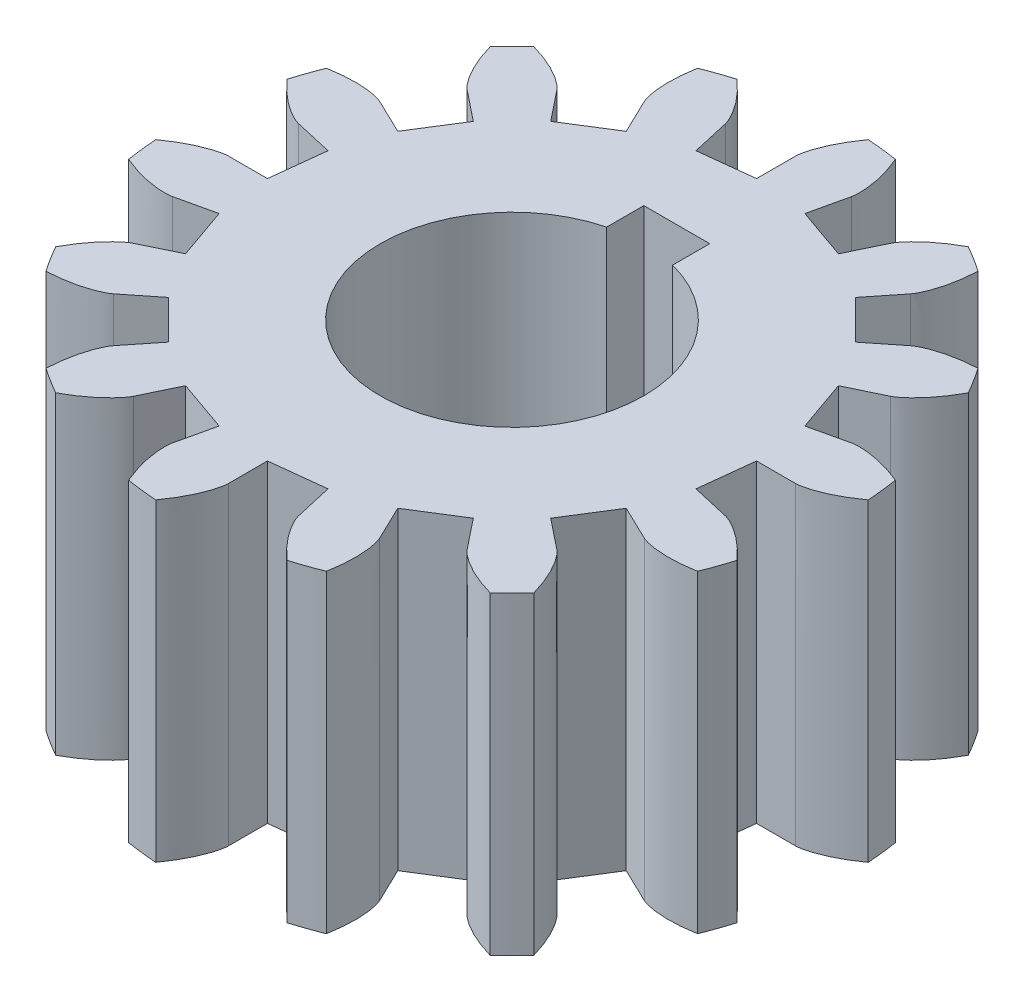
from build123d import *

# Parameters (mm, degrees)
EXTRUDE1_DEPTH = 9.525


with BuildPart() as part:
    # Sketch1 → Extrude1 (new body)
    with BuildSketch(Plane(origin=(0, 0, 0), x_dir=(1, 0, 0), z_dir=(0, 1, 0))):
        with BuildLine():
            Line((-8.606832516, 0.000361307), (-7.420609993, 0.00031151))
            Line((-7.420609993, 0.00031151), (-7.23449049, 1.651544767))
            Line((-7.23449049, 1.651544767), (-8.390960857, 1.915552658))
            add(Edge.make_bspline(
                [(-9.734164993, 2.910606791), (-9.702640301, 2.874721393), (-9.615405681, 2.777030976), (-9.471436244, 2.630567585), (-9.305885248, 2.477164851), (-9.149280434, 2.346244393), (-9.003474536, 2.236233765), (-8.870105965, 2.145762103), (-8.750724618, 2.073252804), (-8.646732539, 2.017110172), (-8.559453592, 1.975444852), (-8.489935237, 1.946810097), (-8.436064686, 1.927132829), (-8.404839359, 1.919115891), (-8.390960857, 1.915552658)],
                knots=[0.068877552, 0.068877552, 0.068877552, 0.068877552, 0.148294695, 0.284329409, 0.408535099, 0.520911772, 0.621459441, 0.710178123, 0.787067842, 0.852128636, 0.905360569, 0.946763757, 0.976338459, 1, 1, 1, 1], degree=3))
            ThreePointArc((-9.734164993, 2.910606791), (-9.589713761, 3.35603784), (-9.424891766, 3.794339891))
            add(Edge.make_bspline(
                [(-9.424891766, 3.794339891), (-9.377869884, 3.802736953), (-9.248756288, 3.82471366), (-9.044875942, 3.849442758), (-8.819796518, 3.866139589), (-8.615729979, 3.870838688), (-8.433144244, 3.86592464), (-8.272465382, 3.8534908), (-8.133921968, 3.835736168), (-8.017615087, 3.814782479), (-7.923401591, 3.792932295), (-7.851198234, 3.7719698), (-7.796813494, 3.753761803), (-7.76740318, 3.740558555), (-7.754331383, 3.7346902)],
                knots=[0.068877552, 0.068877552, 0.068877552, 0.068877552, 0.148294695, 0.284329409, 0.408535099, 0.520911772, 0.621459441, 0.710178123, 0.787067842, 0.852128636, 0.905360569, 0.946763757, 0.976338459, 1, 1, 1, 1], degree=3))
            Line((-7.754331383, 3.7346902), (-6.685603426, 3.219962672))
            Line((-6.685603426, 3.219962672), (-5.801472288, 4.626918203))
            Line((-5.801472288, 4.626918203), (-6.728867354, 5.366554781))
            add(Edge.make_bspline(
                [(-7.507314656, 6.845862009), (-7.494481981, 6.799852332), (-7.458272587, 6.673986625), (-7.392108691, 6.479561671), (-7.309511348, 6.269520698), (-7.225219545, 6.083617159), (-7.141584792, 5.9212382), (-7.060678046, 5.781859595), (-6.984579774, 5.664733349), (-6.915245523, 5.569030113), (-6.854687814, 5.493622042), (-6.804478095, 5.437660135), (-6.764480052, 5.396557972), (-6.739825424, 5.375786799), (-6.728867354, 5.366554781)],
                knots=[0.068877552, 0.068877552, 0.068877552, 0.068877552, 0.148294695, 0.284329409, 0.408535099, 0.520911772, 0.621459441, 0.710178123, 0.787067842, 0.852128636, 0.905360569, 0.946763757, 0.976338459, 1, 1, 1, 1], degree=3))
            ThreePointArc((-7.507314656, 6.845862009), (-7.183903304, 7.184506477), (-6.845231685, 7.507889396))
            add(Edge.make_bspline(
                [(-6.845231685, 7.507889396), (-6.799223085, 7.495052858), (-6.673360418, 7.458832897), (-6.47894102, 7.392652677), (-6.268906983, 7.3100377), (-6.083010522, 7.225730289), (-5.920638585, 7.142081904), (-5.781266773, 7.061163455), (-5.664146916, 6.98505535), (-5.568449502, 6.915713064), (-5.493046515, 6.855149024), (-5.437088824, 6.804934607), (-5.39599002, 6.764933114), (-5.375220917, 6.740276742), (-5.365989819, 6.729317896)],
                knots=[0.068877552, 0.068877552, 0.068877552, 0.068877552, 0.148294695, 0.284329409, 0.408535099, 0.520911772, 0.621459441, 0.710178123, 0.787067842, 0.852128636, 0.905360569, 0.946763757, 0.976338459, 1, 1, 1, 1], degree=3))
            Line((-5.365989819, 6.729317896), (-4.626431106, 5.801860736))
            Line((-4.626431106, 5.801860736), (-3.219401349, 6.685873744))
            Line((-3.219401349, 6.685873744), (-3.734039148, 7.754644913))
            add(Edge.make_bspline(
                [(-3.793548581, 9.425210298), (-3.801949591, 9.378189122), (-3.823937138, 9.249077371), (-3.848683353, 9.045199102), (-3.865399082, 8.820121081), (-3.870115313, 8.616054937), (-3.865216595, 8.433468791), (-3.852796245, 8.272788885), (-3.835053245, 8.134243981), (-3.814109321, 8.017935341), (-3.792267047, 7.923720011), (-3.771310615, 7.851514894), (-3.753107183, 7.797128625), (-3.739906405, 7.767717203), (-3.734039148, 7.754644913)],
                knots=[0.068877552, 0.068877552, 0.068877552, 0.068877552, 0.148294695, 0.284329409, 0.408535099, 0.520911772, 0.621459441, 0.710178123, 0.787067842, 0.852128636, 0.905360569, 0.946763757, 0.976338459, 1, 1, 1, 1], degree=3))
            ThreePointArc((-3.793548581, 9.425210298), (-3.355232693, 9.589995494), (-2.909789518, 9.734409328))
            add(Edge.make_bspline(
                [(-2.909789518, 9.734409328), (-2.873906766, 9.702881623), (-2.776223674, 9.615638802), (-2.629772371, 9.471657069), (-2.476383537, 9.306093193), (-2.345476227, 9.149477388), (-2.235477842, 9.003662254), (-2.145017377, 8.870286088), (-2.072518102, 8.750898654), (-2.016384201, 8.646901862), (-1.974726209, 8.559619417), (-1.94609729, 8.490098658), (-1.926424545, 8.436226455), (-1.918410229, 8.405000455), (-1.914848162, 8.391121654)],
                knots=[0.068877552, 0.068877552, 0.068877552, 0.068877552, 0.148294695, 0.284329409, 0.408535099, 0.520911772, 0.621459441, 0.710178123, 0.787067842, 0.852128636, 0.905360569, 0.946763757, 0.976338459, 1, 1, 1, 1], degree=3))
            Line((-1.914848162, 8.391121654), (-1.650937366, 7.234629126))
            Line((-1.650937366, 7.234629126), (0.00031151, 7.420609993))
            Line((0.00031151, 7.420609993), (0.000361307, 8.606832516))
            add(Edge.make_bspline(
                [(0.671576316, 10.137780095), (0.643605544, 10.09906054), (0.567775959, 9.992274912), (0.457020924, 9.819323919), (0.344302879, 9.623788312), (0.25151272, 9.441977365), (0.176705153, 9.275347458), (0.118179103, 9.125190877), (0.074052613, 8.992667832), (0.042458008, 8.878790141), (0.021258718, 8.784428053), (0.008811185, 8.710280836), (0.001614592, 8.653382328), (0.000746944, 8.621155949), (0.000361307, 8.606832516)],
                knots=[0.068877552, 0.068877552, 0.068877552, 0.068877552, 0.148294695, 0.284329409, 0.408535099, 0.520911772, 0.621459441, 0.710178123, 0.787067842, 0.852128636, 0.905360569, 0.946763757, 0.976338459, 1, 1, 1, 1], degree=3))
            ThreePointArc((0.671576316, 10.137780095), (1.137982902, 10.09606829), (1.60197215, 10.032910108))
            add(Edge.make_bspline(
                [(1.60197215, 10.032910108), (1.620622033, 9.988935685), (1.670778216, 9.867949514), (1.740254949, 9.674683616), (1.80661804, 9.458962797), (1.856608399, 9.26105828), (1.892446705, 9.081956873), (1.916079017, 8.922539775), (1.929598341, 8.783519157), (1.935050721, 8.665465698), (1.934712841, 8.568752207), (1.930342678, 8.493694545), (1.924692937, 8.436621683), (1.918365133, 8.405010748), (1.915552658, 8.390960857)],
                knots=[0.068877552, 0.068877552, 0.068877552, 0.068877552, 0.148294695, 0.284329409, 0.408535099, 0.520911772, 0.621459441, 0.710178123, 0.787067842, 0.852128636, 0.905360569, 0.946763757, 0.976338459, 1, 1, 1, 1], degree=3))
            Line((1.915552658, 8.390960857), (1.651544767, 7.23449049))
            Line((1.651544767, 7.23449049), (3.219962672, 6.685603426))
            Line((3.219962672, 6.685603426), (3.7346902, 7.754331383))
            add(Edge.make_bspline(
                [(5.003687287, 8.842438212), (4.961686707, 8.819689162), (4.847034064, 8.756379859), (4.672206602, 8.648611207), (4.485811433, 8.521346239), (4.323325574, 8.397800378), (4.183628278, 8.280129806), (4.06574763, 8.170236903), (3.968491443, 8.069983532), (3.890616009, 7.981091662), (3.830573933, 7.905272386), (3.787187821, 7.843868834), (3.756016578, 7.795727535), (3.741252352, 7.767069029), (3.7346902, 7.754331383)],
                knots=[0.068877552, 0.068877552, 0.068877552, 0.068877552, 0.148294695, 0.284329409, 0.408535099, 0.520911772, 0.621459441, 0.710178123, 0.787067842, 0.852128636, 0.905360569, 0.946763757, 0.976338459, 1, 1, 1, 1], degree=3))
            ThreePointArc((5.003687287, 8.842438212), (5.405807027, 8.602490941), (5.796443586, 8.344269995))
            add(Edge.make_bspline(
                [(5.796443586, 8.344269995), (5.794166763, 8.296558528), (5.786861991, 8.165791802), (5.765603433, 7.96152042), (5.731796756, 7.738368813), (5.690968962, 7.538373), (5.645548971, 7.36145855), (5.597672463, 7.207575032), (5.549534167, 7.076455968), (5.503225115, 6.967727777), (5.460958285, 6.880738534), (5.424454606, 6.81501006), (5.394601378, 6.766040519), (5.375184753, 6.740305582), (5.366554781, 6.728867354)],
                knots=[0.068877552, 0.068877552, 0.068877552, 0.068877552, 0.148294695, 0.284329409, 0.408535099, 0.520911772, 0.621459441, 0.710178123, 0.787067842, 0.852128636, 0.905360569, 0.946763757, 0.976338459, 1, 1, 1, 1], degree=3))
            Line((5.366554781, 6.728867354), (4.626918203, 5.801472288))
            Line((4.626918203, 5.801472288), (5.801860736, 4.626431106))
            Line((5.801860736, 4.626431106), (6.729317896, 5.365989819))
            add(Edge.make_bspline(
                [(8.344756625, 5.795742996), (8.297044967, 5.793470179), (8.166277628, 5.786176385), (7.962004462, 5.764934978), (7.738850017, 5.731147037), (7.538850777, 5.690336034), (7.361932514, 5.644930897), (7.208044977, 5.597067308), (7.076921872, 5.548940021), (6.968189794, 5.502640098), (6.881197002, 5.460380571), (6.815465463, 5.423882411), (6.766493416, 5.394033294), (6.740756849, 5.37461883), (6.729317896, 5.365989819)],
                knots=[0.068877552, 0.068877552, 0.068877552, 0.068877552, 0.148294695, 0.284329409, 0.408535099, 0.520911772, 0.621459441, 0.710178123, 0.787067842, 0.852128636, 0.905360569, 0.946763757, 0.976338459, 1, 1, 1, 1], degree=3))
            ThreePointArc((8.344756625, 5.795742996), (8.602944772, 5.405084758), (8.842858281, 5.002944874))
            add(Edge.make_bspline(
                [(8.842858281, 5.002944874), (8.820105705, 4.960946204), (8.756786776, 4.846298877), (8.649003447, 4.671480464), (8.52172283, 4.48509598), (8.398163327, 4.322620495), (8.280481026, 4.182933079), (8.170578227, 4.065061658), (8.070316691, 3.967813887), (7.981418283, 3.889945917), (7.905593967, 3.829910207), (7.844186772, 3.786529251), (7.796042856, 3.75536205), (7.76738311, 3.74060023), (7.754644913, 3.734039148)],
                knots=[0.068877552, 0.068877552, 0.068877552, 0.068877552, 0.148294695, 0.284329409, 0.408535099, 0.520911772, 0.621459441, 0.710178123, 0.787067842, 0.852128636, 0.905360569, 0.946763757, 0.976338459, 1, 1, 1, 1], degree=3))
            Line((7.754644913, 3.734039148), (6.685873744, 3.219401349))
            Line((6.685873744, 3.219401349), (7.234629126, 1.650937366))
            Line((7.234629126, 1.650937366), (8.391121654, 1.914848162))
            add(Edge.make_bspline(
                [(10.033044571, 1.601129799), (9.989071714, 1.619783374), (9.868089755, 1.669949715), (9.67482969, 1.739442674), (9.459114444, 1.805823876), (9.261214125, 1.855830851), (9.082115727, 1.891684193), (8.922700614, 1.91532989), (8.783681131, 1.928860885), (8.66562813, 1.934323177), (8.568914612, 1.933993417), (8.493856583, 1.929629556), (8.436783247, 1.923984607), (8.405171781, 1.917659457), (8.391121654, 1.914848162)],
                knots=[0.068877552, 0.068877552, 0.068877552, 0.068877552, 0.148294695, 0.284329409, 0.408535099, 0.520911772, 0.621459441, 0.710178123, 0.787067842, 0.852128636, 0.905360569, 0.946763757, 0.976338459, 1, 1, 1, 1], degree=3))
            ThreePointArc((10.033044571, 1.601129799), (10.096163797, 1.13713525), (10.137836443, 0.670725164))
            add(Edge.make_bspline(
                [(10.137836443, 0.670725164), (10.099114541, 0.642757643), (9.992322546, 0.566937024), (9.819362255, 0.45619651), (9.623817185, 0.343494882), (9.441998449, 0.250719988), (9.275362261, 0.175926411), (9.125200767, 0.117412968), (8.992674018, 0.073297605), (8.878793674, 0.041712561), (8.784429807, 0.020521193), (8.710281545, 0.008079886), (8.653382434, 0.00088807), (8.621155982, 2.3128e-05), (8.606832516, -0.000361307)],
                knots=[0.068877552, 0.068877552, 0.068877552, 0.068877552, 0.148294695, 0.284329409, 0.408535099, 0.520911772, 0.621459441, 0.710178123, 0.787067842, 0.852128636, 0.905360569, 0.946763757, 0.976338459, 1, 1, 1, 1], degree=3))
            Line((8.606832516, -0.000361307), (7.420609993, -0.00031151))
            Line((7.420609993, -0.00031151), (7.23449049, -1.651544767))
            Line((7.23449049, -1.651544767), (8.390960857, -1.915552658))
            add(Edge.make_bspline(
                [(9.734164993, -2.910606791), (9.702640301, -2.874721393), (9.615405681, -2.777030976), (9.471436244, -2.630567585), (9.305885248, -2.477164851), (9.149280434, -2.346244393), (9.003474536, -2.236233765), (8.870105965, -2.145762103), (8.750724618, -2.073252804), (8.646732539, -2.017110172), (8.559453592, -1.975444852), (8.489935237, -1.946810097), (8.436064686, -1.927132829), (8.404839359, -1.919115891), (8.390960857, -1.915552658)],
                knots=[0.068877552, 0.068877552, 0.068877552, 0.068877552, 0.148294695, 0.284329409, 0.408535099, 0.520911772, 0.621459441, 0.710178123, 0.787067842, 0.852128636, 0.905360569, 0.946763757, 0.976338459, 1, 1, 1, 1], degree=3))
            ThreePointArc((9.734164993, -2.910606791), (9.589713761, -3.35603784), (9.424891766, -3.794339891))
            add(Edge.make_bspline(
                [(9.424891766, -3.794339891), (9.377869884, -3.802736953), (9.248756288, -3.82471366), (9.044875942, -3.849442758), (8.819796518, -3.866139589), (8.615729979, -3.870838688), (8.433144244, -3.86592464), (8.272465382, -3.8534908), (8.133921968, -3.835736168), (8.017615087, -3.814782479), (7.923401591, -3.792932295), (7.851198234, -3.7719698), (7.796813494, -3.753761803), (7.76740318, -3.740558555), (7.754331383, -3.7346902)],
                knots=[0.068877552, 0.068877552, 0.068877552, 0.068877552, 0.148294695, 0.284329409, 0.408535099, 0.520911772, 0.621459441, 0.710178123, 0.787067842, 0.852128636, 0.905360569, 0.946763757, 0.976338459, 1, 1, 1, 1], degree=3))
            Line((7.754331383, -3.7346902), (6.685603426, -3.219962672))
            Line((6.685603426, -3.219962672), (5.801472288, -4.626918203))
            Line((5.801472288, -4.626918203), (6.728867354, -5.366554781))
            add(Edge.make_bspline(
                [(7.507314656, -6.845862009), (7.494481981, -6.799852332), (7.458272587, -6.673986625), (7.392108691, -6.479561671), (7.309511348, -6.269520698), (7.225219545, -6.083617159), (7.141584792, -5.9212382), (7.060678046, -5.781859595), (6.984579774, -5.664733349), (6.915245523, -5.569030113), (6.854687814, -5.493622042), (6.804478095, -5.437660135), (6.764480052, -5.396557972), (6.739825424, -5.375786799), (6.728867354, -5.366554781)],
                knots=[0.068877552, 0.068877552, 0.068877552, 0.068877552, 0.148294695, 0.284329409, 0.408535099, 0.520911772, 0.621459441, 0.710178123, 0.787067842, 0.852128636, 0.905360569, 0.946763757, 0.976338459, 1, 1, 1, 1], degree=3))
            ThreePointArc((7.507314656, -6.845862009), (7.183903304, -7.184506477), (6.845231685, -7.507889396))
            add(Edge.make_bspline(
                [(6.845231685, -7.507889396), (6.799223085, -7.495052858), (6.673360418, -7.458832897), (6.47894102, -7.392652677), (6.268906983, -7.3100377), (6.083010522, -7.225730289), (5.920638585, -7.142081904), (5.781266773, -7.061163455), (5.664146916, -6.98505535), (5.568449502, -6.915713064), (5.493046515, -6.855149024), (5.437088824, -6.804934607), (5.39599002, -6.764933114), (5.375220917, -6.740276742), (5.365989819, -6.729317896)],
                knots=[0.068877552, 0.068877552, 0.068877552, 0.068877552, 0.148294695, 0.284329409, 0.408535099, 0.520911772, 0.621459441, 0.710178123, 0.787067842, 0.852128636, 0.905360569, 0.946763757, 0.976338459, 1, 1, 1, 1], degree=3))
            Line((5.365989819, -6.729317896), (4.626431106, -5.801860736))
            Line((4.626431106, -5.801860736), (3.219401349, -6.685873744))
            Line((3.219401349, -6.685873744), (3.734039148, -7.754644913))
            add(Edge.make_bspline(
                [(3.793548581, -9.425210298), (3.801949591, -9.378189122), (3.823937138, -9.249077371), (3.848683353, -9.045199102), (3.865399082, -8.820121081), (3.870115313, -8.616054937), (3.865216595, -8.433468791), (3.852796245, -8.272788885), (3.835053245, -8.134243981), (3.814109321, -8.017935341), (3.792267047, -7.923720011), (3.771310615, -7.851514894), (3.753107183, -7.797128625), (3.739906405, -7.767717203), (3.734039148, -7.754644913)],
                knots=[0.068877552, 0.068877552, 0.068877552, 0.068877552, 0.148294695, 0.284329409, 0.408535099, 0.520911772, 0.621459441, 0.710178123, 0.787067842, 0.852128636, 0.905360569, 0.946763757, 0.976338459, 1, 1, 1, 1], degree=3))
            ThreePointArc((3.793548581, -9.425210298), (3.355232693, -9.589995494), (2.909789518, -9.734409328))
            add(Edge.make_bspline(
                [(2.909789518, -9.734409328), (2.873906766, -9.702881623), (2.776223674, -9.615638802), (2.629772371, -9.471657069), (2.476383537, -9.306093193), (2.345476227, -9.149477388), (2.235477842, -9.003662254), (2.145017377, -8.870286088), (2.072518102, -8.750898654), (2.016384201, -8.646901862), (1.974726209, -8.559619417), (1.94609729, -8.490098658), (1.926424545, -8.436226455), (1.918410229, -8.405000455), (1.914848162, -8.391121654)],
                knots=[0.068877552, 0.068877552, 0.068877552, 0.068877552, 0.148294695, 0.284329409, 0.408535099, 0.520911772, 0.621459441, 0.710178123, 0.787067842, 0.852128636, 0.905360569, 0.946763757, 0.976338459, 1, 1, 1, 1], degree=3))
            Line((1.914848162, -8.391121654), (1.650937366, -7.234629126))
            Line((1.650937366, -7.234629126), (-0.00031151, -7.420609993))
            Line((-0.00031151, -7.420609993), (-0.000361307, -8.606832516))
            add(Edge.make_bspline(
                [(-0.671576316, -10.137780095), (-0.643605544, -10.09906054), (-0.567775959, -9.992274912), (-0.457020924, -9.819323919), (-0.344302879, -9.623788312), (-0.25151272, -9.441977365), (-0.176705153, -9.275347458), (-0.118179103, -9.125190877), (-0.074052613, -8.992667832), (-0.042458008, -8.878790141), (-0.021258718, -8.784428053), (-0.008811185, -8.710280836), (-0.001614592, -8.653382328), (-0.000746944, -8.621155949), (-0.000361307, -8.606832516)],
                knots=[0.068877552, 0.068877552, 0.068877552, 0.068877552, 0.148294695, 0.284329409, 0.408535099, 0.520911772, 0.621459441, 0.710178123, 0.787067842, 0.852128636, 0.905360569, 0.946763757, 0.976338459, 1, 1, 1, 1], degree=3))
            ThreePointArc((-0.671576316, -10.137780095), (-1.137982902, -10.09606829), (-1.60197215, -10.032910108))
            add(Edge.make_bspline(
                [(-1.60197215, -10.032910108), (-1.620622033, -9.988935685), (-1.670778216, -9.867949514), (-1.740254949, -9.674683616), (-1.80661804, -9.458962797), (-1.856608399, -9.26105828), (-1.892446705, -9.081956873), (-1.916079017, -8.922539775), (-1.929598341, -8.783519157), (-1.935050721, -8.665465698), (-1.934712841, -8.568752207), (-1.930342678, -8.493694545), (-1.924692937, -8.436621683), (-1.918365133, -8.405010748), (-1.915552658, -8.390960857)],
                knots=[0.068877552, 0.068877552, 0.068877552, 0.068877552, 0.148294695, 0.284329409, 0.408535099, 0.520911772, 0.621459441, 0.710178123, 0.787067842, 0.852128636, 0.905360569, 0.946763757, 0.976338459, 1, 1, 1, 1], degree=3))
            Line((-1.915552658, -8.390960857), (-1.651544767, -7.23449049))
            Line((-1.651544767, -7.23449049), (-3.219962672, -6.685603426))
            Line((-3.219962672, -6.685603426), (-3.7346902, -7.754331383))
            add(Edge.make_bspline(
                [(-5.003687287, -8.842438212), (-4.961686707, -8.819689162), (-4.847034064, -8.756379859), (-4.672206602, -8.648611207), (-4.485811433, -8.521346239), (-4.323325574, -8.397800378), (-4.183628278, -8.280129806), (-4.06574763, -8.170236903), (-3.968491443, -8.069983532), (-3.890616009, -7.981091662), (-3.830573933, -7.905272386), (-3.787187821, -7.843868834), (-3.756016578, -7.795727535), (-3.741252352, -7.767069029), (-3.7346902, -7.754331383)],
                knots=[0.068877552, 0.068877552, 0.068877552, 0.068877552, 0.148294695, 0.284329409, 0.408535099, 0.520911772, 0.621459441, 0.710178123, 0.787067842, 0.852128636, 0.905360569, 0.946763757, 0.976338459, 1, 1, 1, 1], degree=3))
            ThreePointArc((-5.003687287, -8.842438212), (-5.405807027, -8.602490941), (-5.796443586, -8.344269995))
            add(Edge.make_bspline(
                [(-5.796443586, -8.344269995), (-5.794166763, -8.296558528), (-5.786861991, -8.165791802), (-5.765603433, -7.96152042), (-5.731796756, -7.738368813), (-5.690968962, -7.538373), (-5.645548971, -7.36145855), (-5.597672463, -7.207575032), (-5.549534167, -7.076455968), (-5.503225115, -6.967727777), (-5.460958285, -6.880738534), (-5.424454606, -6.81501006), (-5.394601378, -6.766040519), (-5.375184753, -6.740305582), (-5.366554781, -6.728867354)],
                knots=[0.068877552, 0.068877552, 0.068877552, 0.068877552, 0.148294695, 0.284329409, 0.408535099, 0.520911772, 0.621459441, 0.710178123, 0.787067842, 0.852128636, 0.905360569, 0.946763757, 0.976338459, 1, 1, 1, 1], degree=3))
            Line((-5.366554781, -6.728867354), (-4.626918203, -5.801472288))
            Line((-4.626918203, -5.801472288), (-5.801860736, -4.626431106))
            Line((-5.801860736, -4.626431106), (-6.729317896, -5.365989819))
            add(Edge.make_bspline(
                [(-8.344756625, -5.795742996), (-8.297044967, -5.793470179), (-8.166277628, -5.786176385), (-7.962004462, -5.764934978), (-7.738850017, -5.731147037), (-7.538850777, -5.690336034), (-7.361932514, -5.644930897), (-7.208044977, -5.597067308), (-7.076921872, -5.548940021), (-6.968189794, -5.502640098), (-6.881197002, -5.460380571), (-6.815465463, -5.423882411), (-6.766493416, -5.394033294), (-6.740756849, -5.37461883), (-6.729317896, -5.365989819)],
                knots=[0.068877552, 0.068877552, 0.068877552, 0.068877552, 0.148294695, 0.284329409, 0.408535099, 0.520911772, 0.621459441, 0.710178123, 0.787067842, 0.852128636, 0.905360569, 0.946763757, 0.976338459, 1, 1, 1, 1], degree=3))
            ThreePointArc((-8.344756625, -5.795742996), (-8.602944772, -5.405084758), (-8.842858281, -5.002944874))
            add(Edge.make_bspline(
                [(-8.842858281, -5.002944874), (-8.820105705, -4.960946204), (-8.756786776, -4.846298877), (-8.649003447, -4.671480464), (-8.52172283, -4.48509598), (-8.398163327, -4.322620495), (-8.280481026, -4.182933079), (-8.170578227, -4.065061658), (-8.070316691, -3.967813887), (-7.981418283, -3.889945917), (-7.905593967, -3.829910207), (-7.844186772, -3.786529251), (-7.796042856, -3.75536205), (-7.76738311, -3.74060023), (-7.754644913, -3.734039148)],
                knots=[0.068877552, 0.068877552, 0.068877552, 0.068877552, 0.148294695, 0.284329409, 0.408535099, 0.520911772, 0.621459441, 0.710178123, 0.787067842, 0.852128636, 0.905360569, 0.946763757, 0.976338459, 1, 1, 1, 1], degree=3))
            Line((-7.754644913, -3.734039148), (-6.685873744, -3.219401349))
            Line((-6.685873744, -3.219401349), (-7.234629126, -1.650937366))
            Line((-7.234629126, -1.650937366), (-8.391121654, -1.914848162))
            add(Edge.make_bspline(
                [(-10.033044571, -1.601129799), (-9.989071714, -1.619783374), (-9.868089755, -1.669949715), (-9.67482969, -1.739442674), (-9.459114444, -1.805823876), (-9.261214125, -1.855830851), (-9.082115727, -1.891684193), (-8.922700614, -1.91532989), (-8.783681131, -1.928860885), (-8.66562813, -1.934323177), (-8.568914612, -1.933993417), (-8.493856583, -1.929629556), (-8.436783247, -1.923984607), (-8.405171781, -1.917659457), (-8.391121654, -1.914848162)],
                knots=[0.068877552, 0.068877552, 0.068877552, 0.068877552, 0.148294695, 0.284329409, 0.408535099, 0.520911772, 0.621459441, 0.710178123, 0.787067842, 0.852128636, 0.905360569, 0.946763757, 0.976338459, 1, 1, 1, 1], degree=3))
            ThreePointArc((-10.033044571, -1.601129799), (-10.096163797, -1.13713525), (-10.137836443, -0.670725164))
            add(Edge.make_bspline(
                [(-10.137836443, -0.670725164), (-10.099114541, -0.642757643), (-9.992322546, -0.566937024), (-9.819362255, -0.45619651), (-9.623817185, -0.343494882), (-9.441998449, -0.250719988), (-9.275362261, -0.175926411), (-9.125200767, -0.117412968), (-8.992674018, -0.073297605), (-8.878793674, -0.041712561), (-8.784429807, -0.020521193), (-8.710281545, -0.008079886), (-8.653382434, -0.00088807), (-8.621155982, -2.3128e-05), (-8.606832516, 0.000361307)],
                knots=[0.068877552, 0.068877552, 0.068877552, 0.068877552, 0.148294695, 0.284329409, 0.408535099, 0.520911772, 0.621459441, 0.710178123, 0.787067842, 0.852128636, 0.905360569, 0.946763757, 0.976338459, 1, 1, 1, 1], degree=3))
        make_face()
        with BuildLine():
            Line((-1, 5), (1, 5))
            Line((1, 5), (1, 3.872983346))
            ThreePointArc((1, 3.872983346), (0, -4), (-1, 3.872983346))
            Line((-1, 3.872983346), (-1, 5))
        make_face(mode=Mode.SUBTRACT)
    extrude(amount=EXTRUDE1_DEPTH)


solid = part.part
